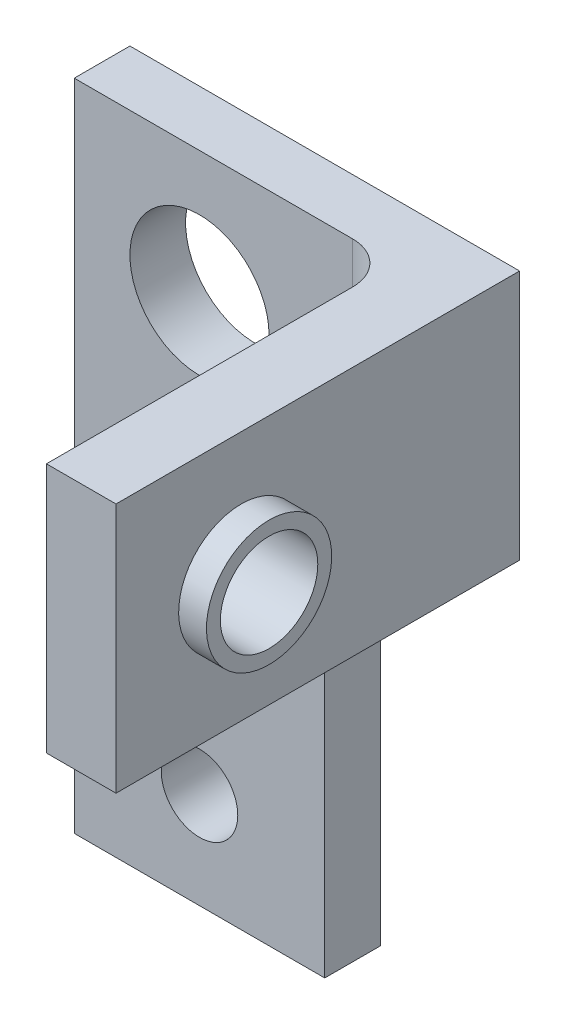
from build123d import *

# Parameters (mm, degrees)
SKETCH1_W           = 9
SKETCH1_H           = 22
BOSS_EXTRUDE1_DEPTH = 2
SKETCH3_R           = 2.5
SKETCH3_R_2         = 1.375
CUT_EXTRUDE1_DEPTH  = 2
SKETCH4_W           = 2
SKETCH4_H           = 9
BOSS_EXTRUDE2_DEPTH = 5
SKETCH5_W           = 2.5
SKETCH5_H           = 9
BOSS_EXTRUDE3_DEPTH = 12.5
SKETCH6_R           = 1.75
CUT_EXTRUDE2_DEPTH  = 2.5
SKETCH14_R          = 2.25
BOSS_EXTRUDE6_DEPTH = 1
SKETCH15_R          = 1.75
CUT_EXTRUDE4_DEPTH  = 1
SKETCH16_R          = 2.25
BOSS_EXTRUDE7_DEPTH = 1
SKETCH17_R          = 1.75
CUT_EXTRUDE5_DEPTH  = 1
FILLET1_R           = 1.5
FILLET2_R           = 1.5
SKETCH18_W          = 9
SKETCH18_H          = 2
BOSS_EXTRUDE8_DEPTH = 1.5


with BuildPart() as part:
    # Sketch1 → Boss-Extrude1 (new body)
    with BuildSketch(Plane.XY):
        Rectangle(SKETCH1_W, SKETCH1_H)
    extrude(amount=BOSS_EXTRUDE1_DEPTH)

    # Sketch3 → Cut-Extrude1 (cut)
    with BuildSketch(Plane.XY.offset(2)):
        with Locations((0, 6.5)):
            Circle(SKETCH3_R)
        with Locations((0, -9)):
            Circle(SKETCH3_R_2)
    extrude(amount=-CUT_EXTRUDE1_DEPTH, mode=Mode.SUBTRACT)

    # Sketch4 → Boss-Extrude2 (add)
    with BuildSketch(Plane(origin=(4.5, 0, 0), x_dir=(0, 0, -1), z_dir=(1, 0, 0))):
        with Locations((-1, 6.5)):
            Rectangle(SKETCH4_W, SKETCH4_H)
    extrude(amount=BOSS_EXTRUDE2_DEPTH)

    # Sketch5 → Boss-Extrude3 (add)
    with BuildSketch(Plane.XY.offset(2)):
        with Locations((8.25, 6.5)):
            Rectangle(SKETCH5_W, SKETCH5_H)
    extrude(amount=BOSS_EXTRUDE3_DEPTH)

    # Sketch6 → Cut-Extrude2 (cut)
    with BuildSketch(Plane.ZY.offset(-7)):
        with Locations((10, 6.5)):
            Circle(SKETCH6_R)
    extrude(amount=-CUT_EXTRUDE2_DEPTH, mode=Mode.SUBTRACT)

    # Sketch14 → Boss-Extrude6 (add)
    with BuildSketch(Plane(origin=(9.5, 0, 0), x_dir=(0, 0, -1), z_dir=(1, 0, 0))):
        with Locations((-10, 6.5)):
            Circle(SKETCH14_R)
    extrude(amount=BOSS_EXTRUDE6_DEPTH)

    # Sketch15 → Cut-Extrude4 (cut)
    with BuildSketch(Plane(origin=(10.5, 0, 0), x_dir=(0, 0, -1), z_dir=(1, 0, 0))):
        with Locations((-10, 6.5)):
            Circle(SKETCH15_R)
    extrude(amount=-CUT_EXTRUDE4_DEPTH, mode=Mode.SUBTRACT)

    # Sketch16 → Boss-Extrude7 (add)
    with BuildSketch(Plane.ZY.offset(-7)):
        with Locations((10, 6.5)):
            Circle(SKETCH16_R)
    extrude(amount=BOSS_EXTRUDE7_DEPTH)

    # Sketch17 → Cut-Extrude5 (cut)
    with BuildSketch(Plane.ZY.offset(-6)):
        with Locations((10, 6.5)):
            Circle(SKETCH17_R)
    extrude(amount=-CUT_EXTRUDE5_DEPTH, mode=Mode.SUBTRACT)

    # Fillet1
    fillet1_edges = [part.edges().sort_by_distance(p)[0] for p in [
        (7, 6.5, 2),
    ]]
    fillet(fillet1_edges, radius=FILLET1_R)

    # Fillet2
    fillet2_edges = [part.edges().sort_by_distance(p)[0] for p in [
        (4.5, 2, 1),
    ]]
    fillet(fillet2_edges, radius=FILLET2_R)

    # Sketch18 → Boss-Extrude8 (add)
    with BuildSketch(Plane.XZ.offset(11)):
        with Locations((0, 1)):
            Rectangle(SKETCH18_W, SKETCH18_H)
    extrude(amount=BOSS_EXTRUDE8_DEPTH)


solid = part.part
